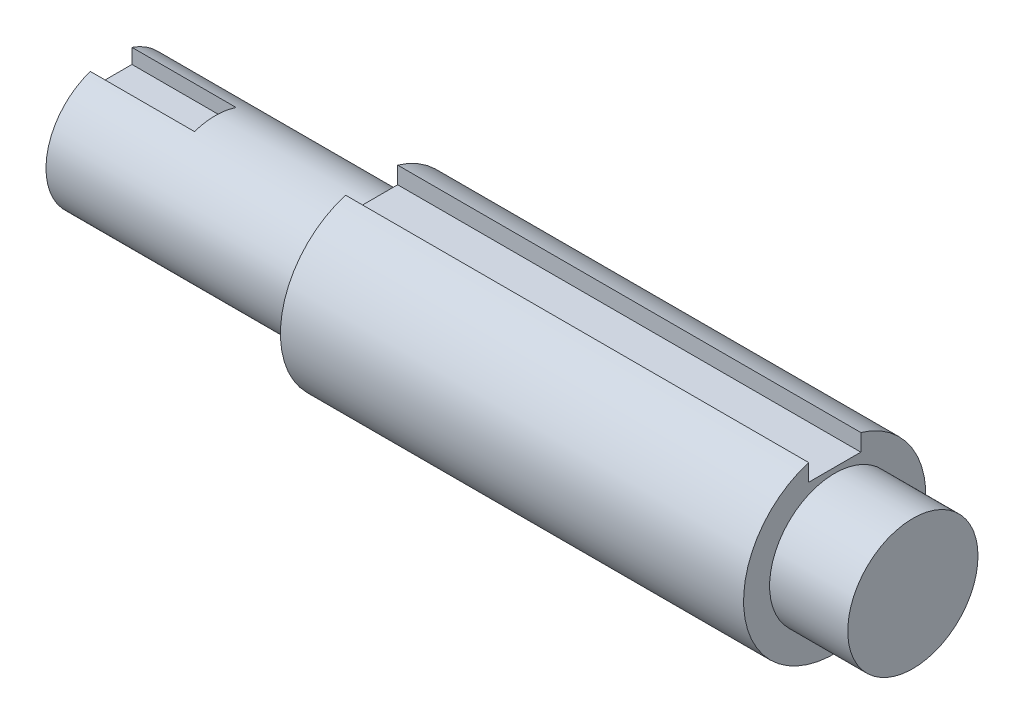
from build123d import *

# Parameters (mm, degrees)
BOSS_EXTRUDE1_DEPTH = 20
SKETCH2_R           = 12.5
BOSS_EXTRUDE2_DEPTH = 10
SKETCH3_R           = 12.5
BOSS_EXTRUDE3_DEPTH = 20
SKETCH4_R           = 12.5
BOSS_EXTRUDE6_DEPTH = 88.9
SKETCH6_R           = 12.5
BOSS_EXTRUDE7_DEPTH = 15


with BuildPart() as part:
    # Sketch1 → Boss-Extrude1 (new body)
    with BuildSketch(Plane(origin=(0, 0, 0), x_dir=(0, 0, -1), z_dir=(1, 0, 0))):
        with BuildLine():
            ThreePointArc((12.5, 0), (10.155048006, 7.288689869), (4, 11.842719282))
            Line((4, 11.842719282), (4, 9))
            Line((4, 9), (-4, 9))
            Line((-4, 9), (-4, 11.842719282))
            ThreePointArc((-4, 11.842719282), (-7.288689869, -10.155048006), (12.5, 0))
        make_face()
    extrude(amount=BOSS_EXTRUDE1_DEPTH)

    # Sketch2 → Boss-Extrude2 (add)
    with BuildSketch(Plane(origin=(20, 0, 0), x_dir=(0, 0, -1), z_dir=(1, 0, 0))):
        with Locations(Location((0, 0, 0), (0, 0, 108.662924885))):
            Circle(SKETCH2_R)
    extrude(amount=BOSS_EXTRUDE2_DEPTH)

    # Sketch3 → Boss-Extrude3 (add)
    with BuildSketch(Plane(origin=(30, 0, 0), x_dir=(0, 0, -1), z_dir=(1, 0, 0))):
        with Locations(Location((0, 0, 0), (0, 0, 108.662924885))):
            Circle(SKETCH3_R)
    extrude(amount=BOSS_EXTRUDE3_DEPTH)

    # Sketch4 → Boss-Extrude6 (add)
    with BuildSketch(Plane(origin=(50, 0, 0), x_dir=(0, 0, -1), z_dir=(1, 0, 0))):
        with BuildLine():
            ThreePointArc((17.5, 0), (14.0312152, 10.458250332), (5, 16.770509831))
            Line((5, 16.770509831), (5, 13.5))
            Line((5, 13.5), (-5, 13.5))
            Line((-5, 13.5), (-5, 16.770509831))
            ThreePointArc((-5, 16.770509831), (-10.458250332, -14.0312152), (17.5, 0))
        make_face()
        with Locations(Location((0, 0, 0), (0, 0, 108.662924885))):
            Circle(SKETCH4_R, mode=Mode.SUBTRACT)
        with Locations(Location((0, 0, 0), (0, 0, 108.662924885))):
            Circle(SKETCH4_R)
    extrude(amount=BOSS_EXTRUDE6_DEPTH)

    # Sketch6 → Boss-Extrude7 (add)
    with BuildSketch(Plane(origin=(138.9, 0, 0), x_dir=(0, 0, -1), z_dir=(1, 0, 0))):
        with Locations(Location((0, 0, 0), (0, 0, 108.662924885))):
            Circle(SKETCH6_R)
    extrude(amount=BOSS_EXTRUDE7_DEPTH)


solid = part.part
